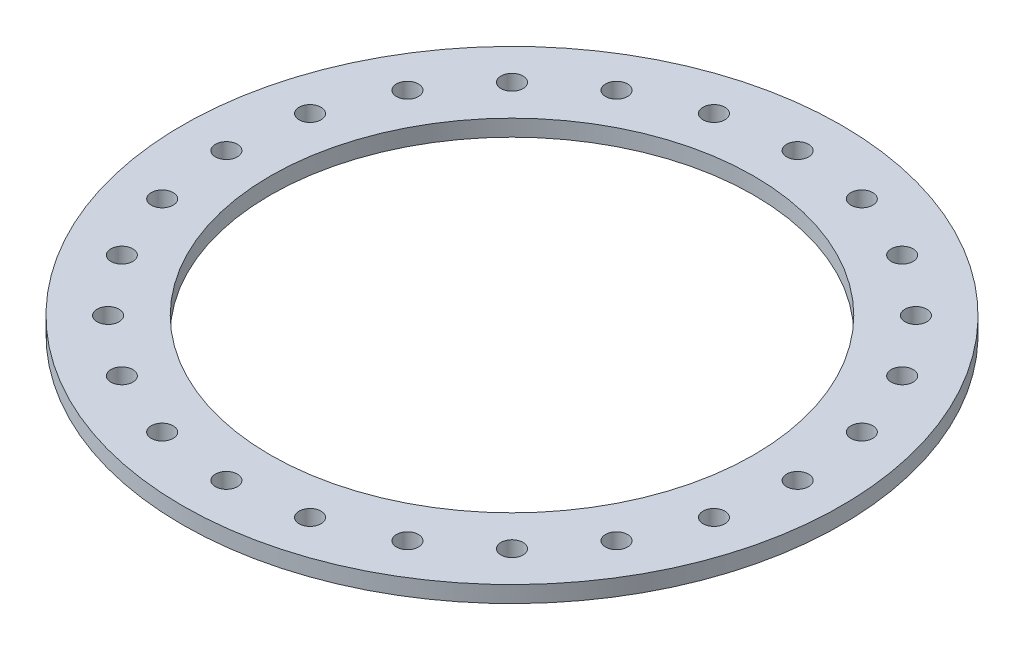
from build123d import *

# Parameters (mm, degrees)
SKETCH1_R           = 381
SKETCH1_R_2         = 279.4
BOSS_EXTRUDE1_DEPTH = 19.05
CIRPATTERN1_COUNT   = 24


with BuildPart() as part:
    # Sketch1 → Boss-Extrude1 (new body)
    with BuildSketch(Plane(origin=(0, 0, 0), x_dir=(1, 0, 0), z_dir=(0, 1, 0))):
        Circle(SKETCH1_R)
        Circle(SKETCH1_R_2, mode=Mode.SUBTRACT)
    extrude(amount=BOSS_EXTRUDE1_DEPTH)

    # Sketch2 → 1 (1) Diameter Hole1 (revolve, cut)
    with BuildSketch(Plane(origin=(0, 19.05, -330.2), x_dir=(0, 0, 1), z_dir=(1, 0, 0))):
        Polygon((0, 0), (0, 39.630929862), (12.7, 32), (12.7, 0), align=None)
    f_1_1_diameter_hole1 = revolve(axis=Axis((0, 25.4, -330.2), (0, -1, 0)), mode=Mode.SUBTRACT)

    # CirPattern1: 1 (1) Diameter Hole1 ×24 about axis
    cirpattern1_axis = Axis((0, 0, 0), (0, 1, 0))
    for i in range(1, CIRPATTERN1_COUNT):
        add(f_1_1_diameter_hole1.rotate(cirpattern1_axis, i * 360 / CIRPATTERN1_COUNT), mode=Mode.SUBTRACT)


solid = part.part
